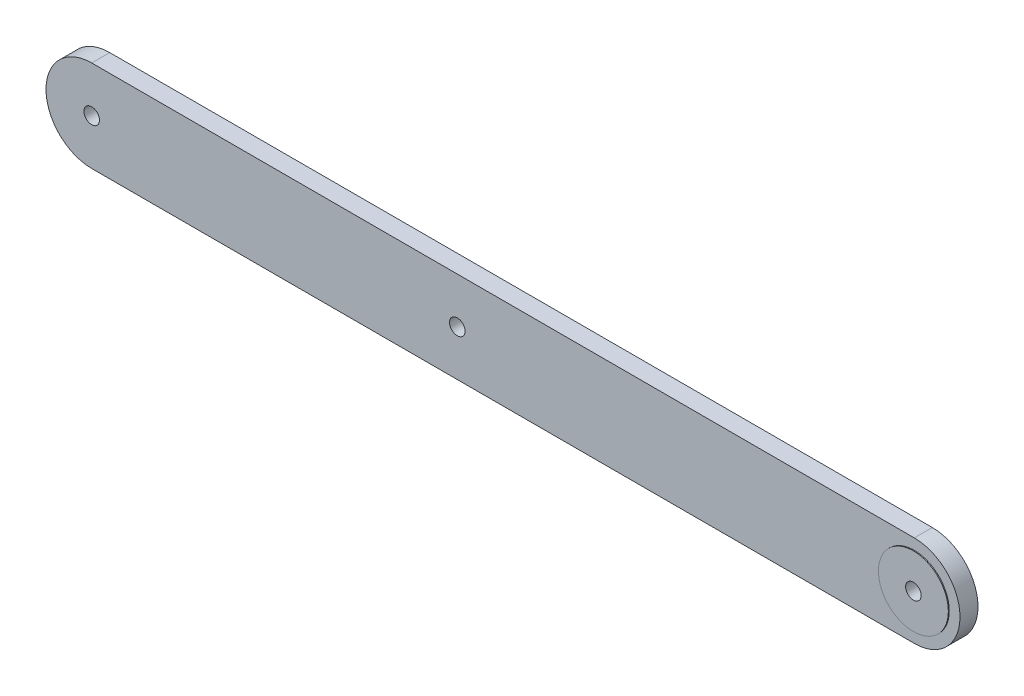
from build123d import *

# Parameters (mm, degrees)
SKETCH1_R                = 6.35
SKETCH1_R_2              = 2.159
BOSS_EXTRUDE1_DEPTH      = 5.0038
SKETCH6_R                = 9.715843696
SKETCH6_R_2              = 2.159
BOSS_EXTRUDE3_DEPTH      = 0.254
BOSS_EXTRUDE3_DEPTH_BACK = 5.0038
SKETCH2_R                = 2.159
CUT_EXTRUDE1_DEPTH       = 19.812


with BuildPart() as part:
    # Sketch1 → Boss-Extrude1 (new body)
    with BuildSketch(Plane.XY):
        with BuildLine():
            Line((-101.6, 12.7), (127, 12.7))
            ThreePointArc((127, 12.7), (139.7, 0), (127, -12.7))
            Line((127, -12.7), (-101.6, -12.7))
            ThreePointArc((-101.6, -12.7), (-114.3, 0), (-101.6, 12.7))
        make_face()
        with Locations((127, 0)):
            Circle(SKETCH1_R, mode=Mode.SUBTRACT)
        with Locations((-101.6, 0)):
            Circle(SKETCH1_R_2, mode=Mode.SUBTRACT)
    extrude(amount=BOSS_EXTRUDE1_DEPTH)

    # Sketch6 → Boss-Extrude3 (add, two sides)
    with BuildSketch(Plane.XY.offset(5.0038)) as boss_extrude3_sk:
        with Locations((127, 0)):
            Circle(SKETCH6_R)
        with Locations((127, 0)):
            Circle(SKETCH6_R_2, mode=Mode.SUBTRACT)
    extrude(amount=BOSS_EXTRUDE3_DEPTH)
    extrude(boss_extrude3_sk.sketch, amount=-BOSS_EXTRUDE3_DEPTH_BACK)

    # Sketch2 → Cut-Extrude1 (cut)
    with BuildSketch(Plane.XY.offset(5.0038)):
        Circle(SKETCH2_R)
    extrude(amount=-CUT_EXTRUDE1_DEPTH, mode=Mode.SUBTRACT)


solid = part.part
